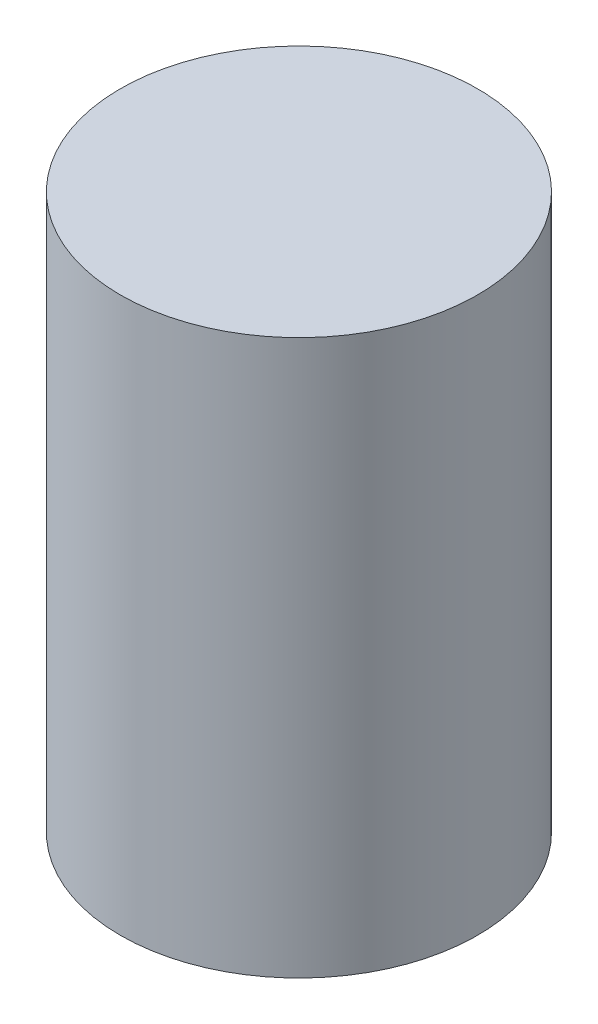
from build123d import *

# Parameters (mm, degrees)
SKETCH1_R           = 28.956
BOSS_EXTRUDE1_DEPTH = 89.916


with BuildPart() as part:
    # Sketch1 → Boss-Extrude1 (new body)
    with BuildSketch(Plane(origin=(0, 0, 0), x_dir=(1, 0, 0), z_dir=(0, 1, 0))):
        Circle(SKETCH1_R)
    extrude(amount=BOSS_EXTRUDE1_DEPTH)


solid = part.part
